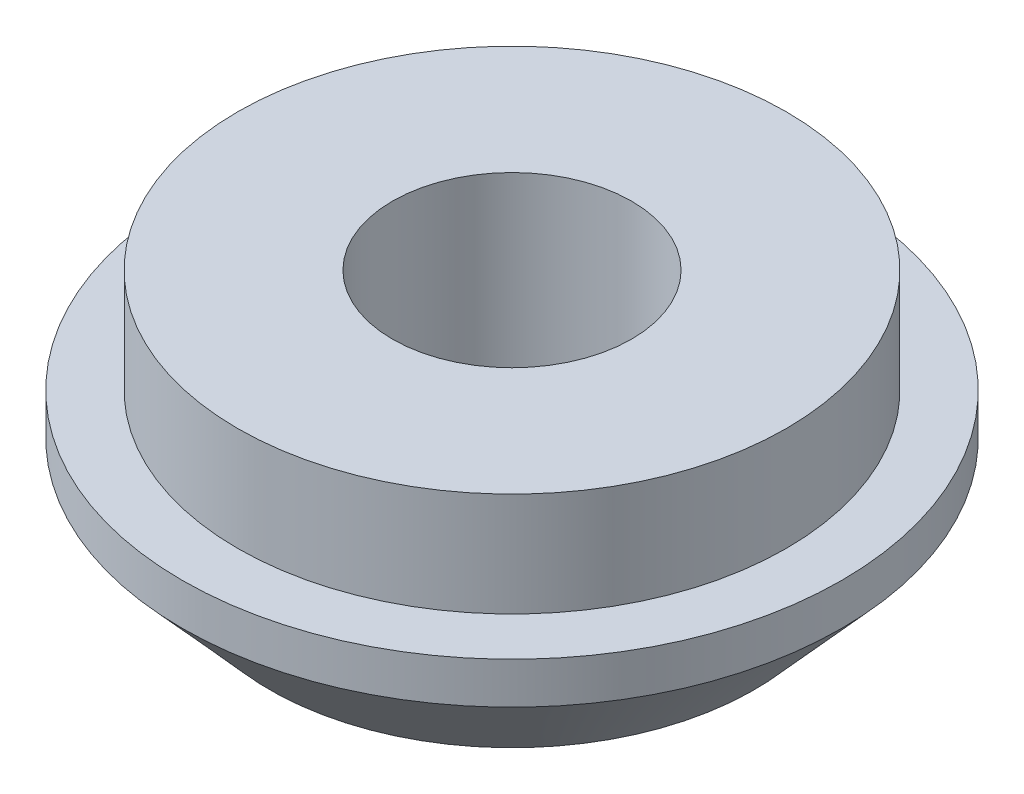
from build123d import *

# Parameters (mm, degrees)
SKETCH1_R                = 9.525
EXTRUDE1_DEPTH           = 7
F_5_16_24_TAPPED_HOLE1_D = 6.9088
SKETCH3_OUTSIDE_W        = 26.618
SKETCH3_OUTSIDE_H        = 26.618
SKETCH3_OUTSIDE_R        = 7.925
EXTRUDE3_DEPTH           = 3


with BuildPart() as part:
    # Sketch1 → Extrude1 (new body)
    with BuildSketch(Plane(origin=(0, 0, 0), x_dir=(1, 0, 0), z_dir=(0, 1, 0))):
        Circle(SKETCH1_R)
    extrude(amount=EXTRUDE1_DEPTH)

    # 5/16-24 Tapped Hole1 (through all)
    with Locations(Plane(origin=(0, 0, 0), x_dir=(-1, 0, 0), z_dir=(0, -1, 0))):
        with Locations((0, 0)):
            Hole(F_5_16_24_TAPPED_HOLE1_D / 2)

    # Sketch3 outside → Extrude3 (cut)
    with BuildSketch(Plane(origin=(0, 7, 0), x_dir=(1, 0, 0), z_dir=(0, 1, 0))):
        Rectangle(SKETCH3_OUTSIDE_W, SKETCH3_OUTSIDE_H)
        Circle(SKETCH3_OUTSIDE_R, mode=Mode.SUBTRACT)
    extrude(amount=-EXTRUDE3_DEPTH, mode=Mode.SUBTRACT)

    # Sketch6 → Cut-Revolve1 (revolve, cut)
    with BuildSketch(Plane.XY):
        Polygon((-9.525, 2.8), (-7, 0), (-7, -3.811390031), (-11.858524977, -3.811390031), (-11.858524977, 2.8), align=None)
    revolve(axis=Axis((0, 0, 0), (0, 1, 0)), mode=Mode.SUBTRACT)


solid = part.part
